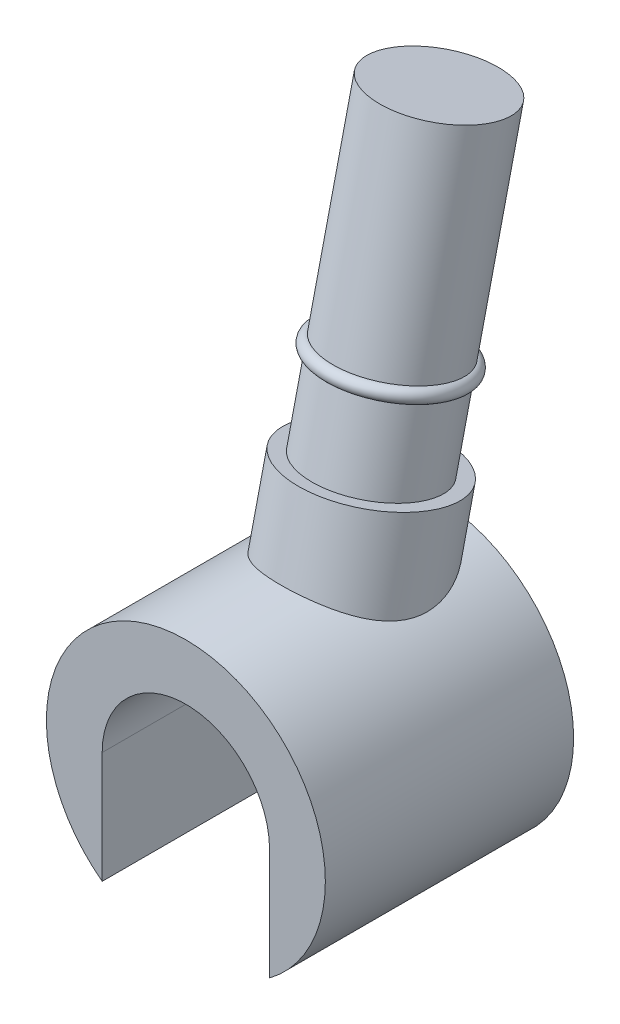
from build123d import *

# Parameters (mm, degrees)
BOSS_EXTRUDE1_DEPTH = 4.45


with BuildPart() as part:
    # Sketch1 → Boss-Extrude1 (new body)
    with BuildSketch(Plane.XY):
        with BuildLine():
            Line((-1.5, 0), (-1.5, -2))
            ThreePointArc((-1.5, -2), (0, 2.5), (1.5, -2))
            Line((1.5, -2), (1.5, 0))
            ThreePointArc((1.5, 0), (0, 1.5), (-1.5, 0))
        make_face()
    extrude(amount=BOSS_EXTRUDE1_DEPTH)

    # Sketch3 → Revolve3 (revolve)
    with BuildSketch(Plane(origin=(0, 0, 0), x_dir=(0, 0, -1), z_dir=(1, 0, 0))):
        with BuildLine():
            Line((0, 2.5), (0.177867067, 3.270426908))
            Line((0.177867067, 3.270426908), (-0.06572545, 3.326664671))
            Line((-0.06572545, 3.326664671), (0.254829803, 4.715142014))
            ThreePointArc((0.254829803, 4.715142014), (0.404744943, 4.80881939), (0.311067566, 4.95873453))
            Line((0.311067566, 4.95873453), (1.149010244, 8.588263021))
            Line((1.149010244, 8.588263021), (0.087181853, 8.833405421))
            Line((0.087181853, 8.833405421), (-1.496634638, 1.973142501))
            Line((-1.496634638, 1.973142501), (-0.191213731, 1.671762337))
            Line((-0.191213731, 1.671762337), (0, 2.5))
        make_face()
    revolve(axis=Axis((0, 8.833405421, -0.087181853), (0, -0.974370065, 0.224951054)))


solid = part.part
